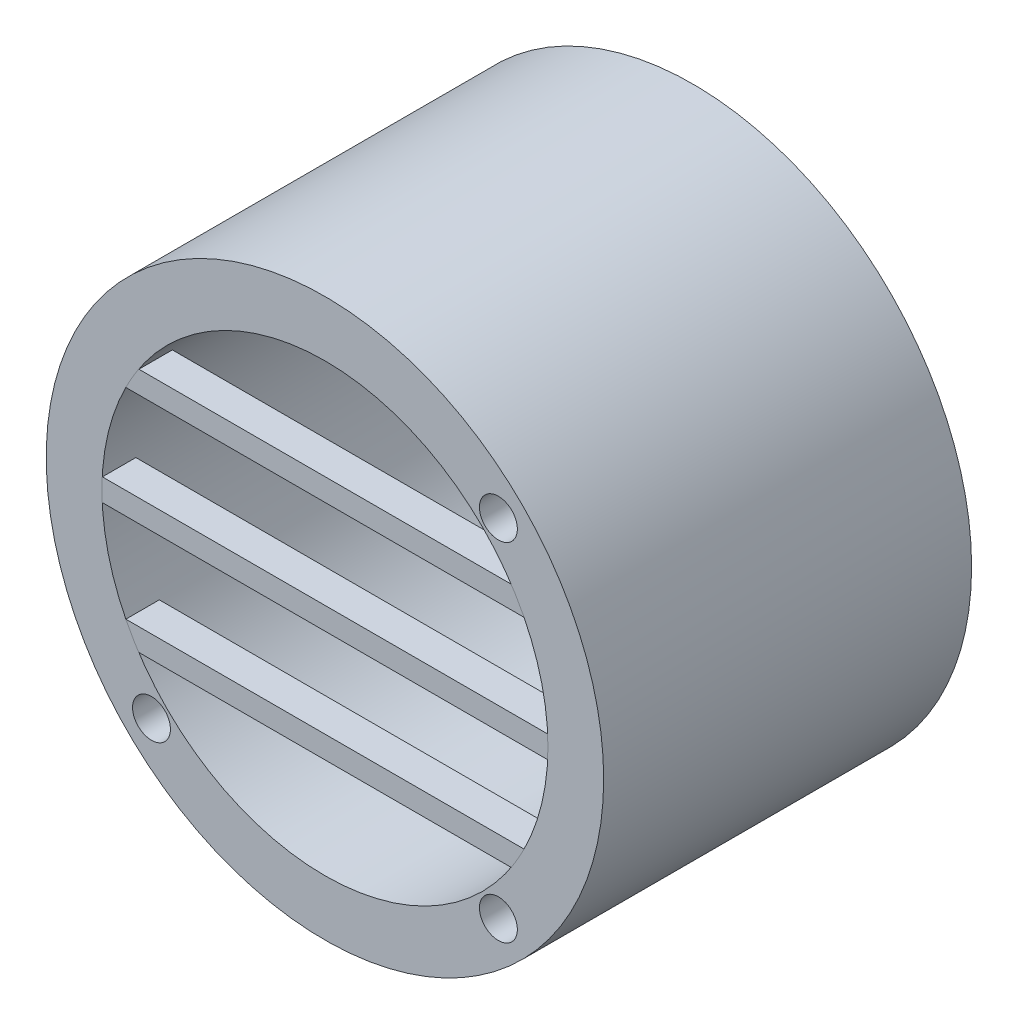
from build123d import *

# Parameters (mm, degrees)
SKETCH2_R                                     = 25
SKETCH2_R_2                                   = 20
BOSS_EXTRUDE1_DEPTH                           = 33
BOSS_EXTRUDE4_DEPTH                           = 3
CBORE_FOR_M3_HEX_HEAD_MACHINE_SCREW1_AT_COUNT = 2
CBORE_FOR_M3_HEX_HEAD_MACHINE_SCREW1_AT_PITCH = 31.112698372
CBORE_FOR_M3_HEX_HEAD_MACHINE_SCREW1_2_COUNT  = 2
CBORE_FOR_M3_HEX_HEAD_MACHINE_SCREW1_2_PITCH  = 44


with BuildPart() as part:
    # Sketch2 → Boss-Extrude1 (new body)
    with BuildSketch(Plane.XY):
        Circle(SKETCH2_R)
        Circle(SKETCH2_R_2, mode=Mode.SUBTRACT)
    extrude(amount=BOSS_EXTRUDE1_DEPTH)

    # Sketch5 → CBORE for M3 Hex Head Machine Screw1 (revolve, cut)
    with BuildSketch(Plane(origin=(15.556349186, 15.556349186, -10), x_dir=(0, 1, 0), z_dir=(1, 0, 0))):
        Polygon((0, 0), (0, 43), (1.7, 43), (1.7, 2.3), (4.2, 2.3), (4.2, 0.025), (4.225, 0), align=None)
    cbore_for_m3_hex_head_machine_screw1 = revolve(axis=Axis((15.556349186, 15.556349186, -16.35), (0, 0, 1)), mode=Mode.SUBTRACT)

    # CBORE for M3 Hex Head Machine Screw1 at: CBORE for M3 Hex Head Machine Screw1 ×2
    with Locations(*[(0, -i * CBORE_FOR_M3_HEX_HEAD_MACHINE_SCREW1_AT_PITCH, 0) for i in range(1, CBORE_FOR_M3_HEX_HEAD_MACHINE_SCREW1_AT_COUNT)]):
        add(cbore_for_m3_hex_head_machine_screw1, mode=Mode.SUBTRACT)

    # CBORE for M3 Hex Head Machine Screw1 2: CBORE for M3 Hex Head Machine Screw1 ×2
    with Locations(*[Vector(-0.707106781, -0.707106781, 0) * (i * CBORE_FOR_M3_HEX_HEAD_MACHINE_SCREW1_2_PITCH) for i in range(1, CBORE_FOR_M3_HEX_HEAD_MACHINE_SCREW1_2_COUNT)]):
        add(cbore_for_m3_hex_head_machine_screw1, mode=Mode.SUBTRACT)


with BuildPart() as body_2:
    # Sketch3 → Boss-Extrude4 (new body)
    with BuildSketch(Plane.XY.offset(33)):
        with BuildLine():
            ThreePointArc((-17.320508076, 10), (-17.597644245, 9.503836963), (-17.860571099, 9))
            Line((-17.860571099, 9), (17.860571099, 9))
            ThreePointArc((17.860571099, 9), (17.597644245, 9.503836963), (17.320508076, 10))
            Line((17.320508076, 10), (-17.320508076, 10))
        make_face()
        with BuildLine():
            ThreePointArc((-16.703293088, 11), (-17.019246793, 10.504534192), (-17.320508076, 10))
            Line((-17.320508076, 10), (17.320508076, 10))
            ThreePointArc((17.320508076, 10), (17.019246793, 10.504534192), (16.703293088, 11))
            Line((16.703293088, 11), (-16.703293088, 11))
        make_face()
        with BuildLine():
            ThreePointArc((-20, 0), (-19.993745111, -0.500156421), (-19.974984355, -1))
            Line((-19.974984355, -1), (19.974984355, -1))
            ThreePointArc((19.974984355, -1), (19.993745111, -0.500156421), (20, 0))
            ThreePointArc((20, 0), (19.993745111, 0.500156421), (19.974984355, 1))
            Line((19.974984355, 1), (-19.974984355, 1))
            ThreePointArc((-19.974984355, 1), (-19.993745111, 0.500156421), (-20, 0))
        make_face()
        with BuildLine():
            ThreePointArc((-17.860571099, -9), (-17.597644245, -9.503836963), (-17.320508076, -10))
            Line((-17.320508076, -10), (17.320508076, -10))
            ThreePointArc((17.320508076, -10), (17.597644245, -9.503836963), (17.860571099, -9))
            Line((17.860571099, -9), (-17.860571099, -9))
        make_face()
        with BuildLine():
            Line((17.320508076, -10), (-17.320508076, -10))
            ThreePointArc((-17.320508076, -10), (-17.019246793, -10.504534192), (-16.703293088, -11))
            Line((-16.703293088, -11), (16.703293088, -11))
            ThreePointArc((16.703293088, -11), (17.019246793, -10.504534192), (17.320508076, -10))
        make_face()
    extrude(amount=-BOSS_EXTRUDE4_DEPTH)


solid = Compound([part.part, body_2.part])
